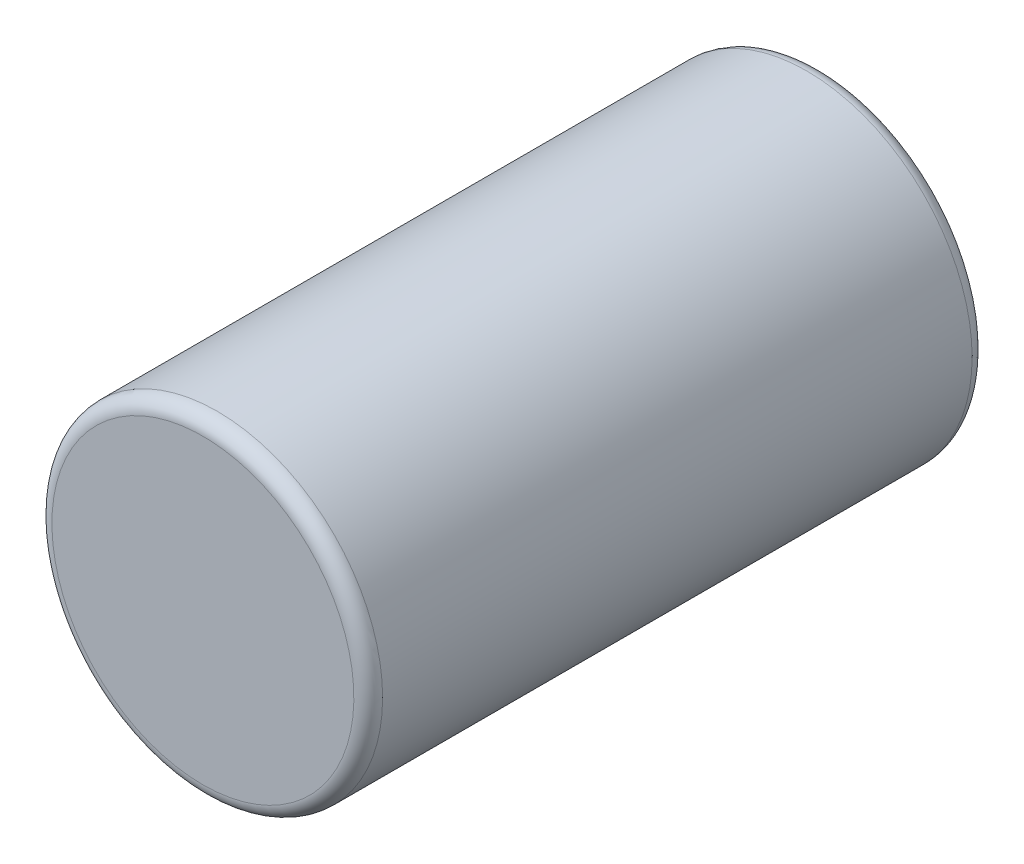
from build123d import *


with BuildPart() as part:
    # Skizze1 → Rotation1 (revolve)
    with BuildSketch(Plane(origin=(0, 0, 0), x_dir=(0, 0, -1), z_dir=(1, 0, 0))):
        with BuildLine():
            Line((0, 0), (0, 10.5))
            ThreePointArc((0, 10.5), (0.292893219, 11.207106781), (1, 11.5))
            Line((1, 11.5), (42, 11.5))
            ThreePointArc((42, 11.5), (42.707106781, 11.207106781), (43, 10.5))
            Line((43, 10.5), (43, 8))
            Line((43, 8), (42.5, 7.5))
            Line((42.5, 7.5), (42.5, 5))
            Line((42.5, 5), (43, 4.5))
            Line((43, 4.5), (43, 0))
            Line((43, 0), (0, 0))
        make_face()
    revolve(axis=Axis((0, 0, 0), (0, 0, -1)))


solid = part.part
